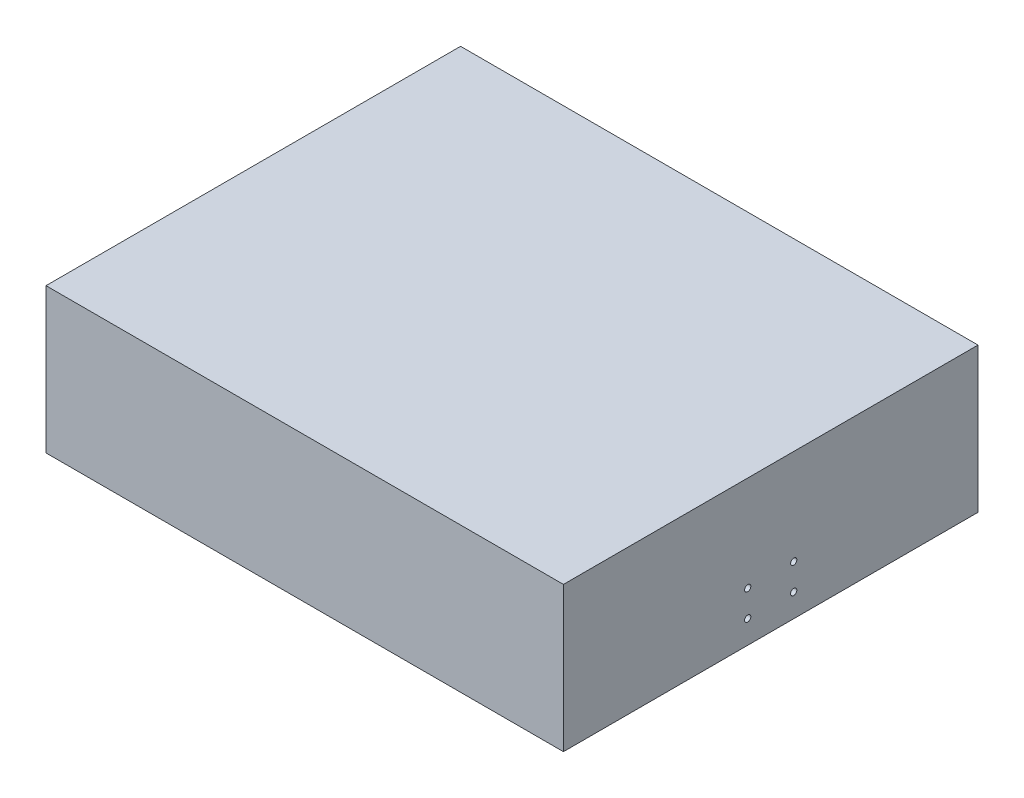
from build123d import *

# Parameters (mm, degrees)
SKETCH1_W           = 250
SKETCH1_H           = 200.3
BOSS_EXTRUDE1_DEPTH = 70
SKETCH2_W           = 230
SKETCH2_H           = 180.3
CUT_EXTRUDE1_DEPTH  = 60
SKETCH3_R           = 1.5
CUT_EXTRUDE2_DEPTH  = 5
SKETCH4_R           = 2.5
CUT_EXTRUDE3_DEPTH  = 8


with BuildPart() as part:
    # Sketch1 → Boss-Extrude1 (new body)
    with BuildSketch(Plane(origin=(0, 0, 0), x_dir=(1, 0, 0), z_dir=(0, 1, 0))):
        Rectangle(SKETCH1_W, SKETCH1_H)
    extrude(amount=BOSS_EXTRUDE1_DEPTH)

    # Sketch2 → Cut-Extrude1 (cut)
    with BuildSketch(Plane.XZ):
        Rectangle(SKETCH2_W, SKETCH2_H)
    extrude(amount=-CUT_EXTRUDE1_DEPTH, mode=Mode.SUBTRACT)

    # Sketch3 → Cut-Extrude2 (cut)
    with BuildSketch(Plane(origin=(125, 0, 0), x_dir=(0, 0, -1), z_dir=(1, 0, 0))):
        with Locations((-11.115, 23.9)):
            Circle(SKETCH3_R)
        with Locations((11.11, 23.900076156)):
            Circle(SKETCH3_R)
        with Locations((-11.115, 11.2)):
            Circle(SKETCH3_R)
        with Locations((11.11, 11.2)):
            Circle(SKETCH3_R)
    extrude(amount=-CUT_EXTRUDE2_DEPTH, mode=Mode.SUBTRACT)

    # Sketch4 → Cut-Extrude3 (cut)
    with BuildSketch(Plane.XZ):
        with Locations((-100.15, 95.15)):
            Circle(SKETCH4_R)
        with Locations((-100.15, -95.15)):
            Circle(SKETCH4_R)
        with Locations((110, -95.15)):
            Circle(SKETCH4_R)
        with Locations((110, 95.15)):
            Circle(SKETCH4_R)
    extrude(amount=-CUT_EXTRUDE3_DEPTH, mode=Mode.SUBTRACT)


solid = part.part
